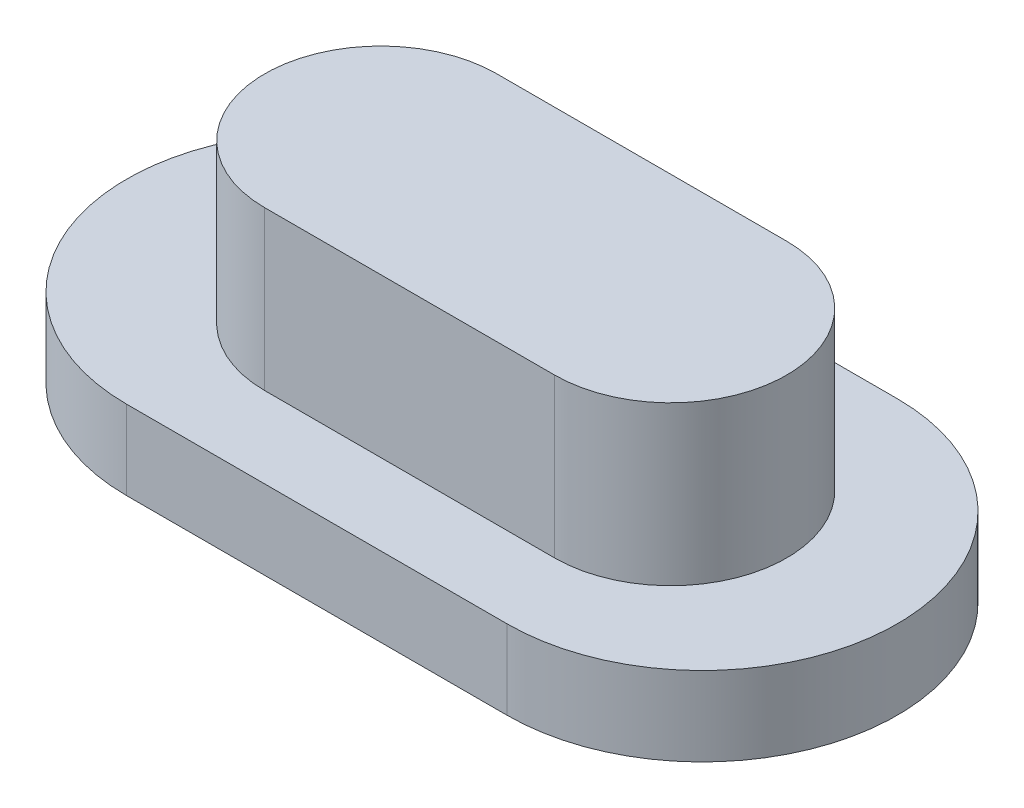
from build123d import *

# Parameters (mm, degrees)
EXTRUDE_1_DEPTH = 2
EXTRUDE_2_DEPTH = 4


with BuildPart() as part:
    # 草图1 → 凸台-拉伸1 (new body)
    with BuildSketch(Plane(origin=(0, 0, 0), x_dir=(1, 0, 0), z_dir=(0, 1, 0))):
        with BuildLine():
            Line((-10.36417176, 0.953563282), (-0.75738839, 0.953563282))
            ThreePointArc((-0.75738839, 0.953563282), (4.168182633, -3.972007741), (-0.75738839, -8.897578764))
            Line((-0.75738839, -8.897578764), (-10.36417176, -8.897578764))
            ThreePointArc((-10.36417176, -8.897578764), (-15.289742784, -3.972007741), (-10.36417176, 0.953563282))
        make_face()
    extrude(amount=EXTRUDE_1_DEPTH)

    # 草图2 → 凸台-拉伸2 (add)
    with BuildSketch(Plane(origin=(0, 2, 0), x_dir=(1, 0, 0), z_dir=(0, 1, 0))):
        with BuildLine():
            Line((-8.92046187, -0.998228401), (-1.597644475, -0.998228401))
            ThreePointArc((-1.597644475, -0.998228401), (1.331482483, -3.927355359), (-1.597644475, -6.856482317))
            Line((-1.597644475, -6.856482317), (-8.92046187, -6.856482317))
            ThreePointArc((-8.92046187, -6.856482317), (-11.849588828, -3.927355359), (-8.92046187, -0.998228401))
        make_face()
    extrude(amount=EXTRUDE_2_DEPTH)


solid = part.part
